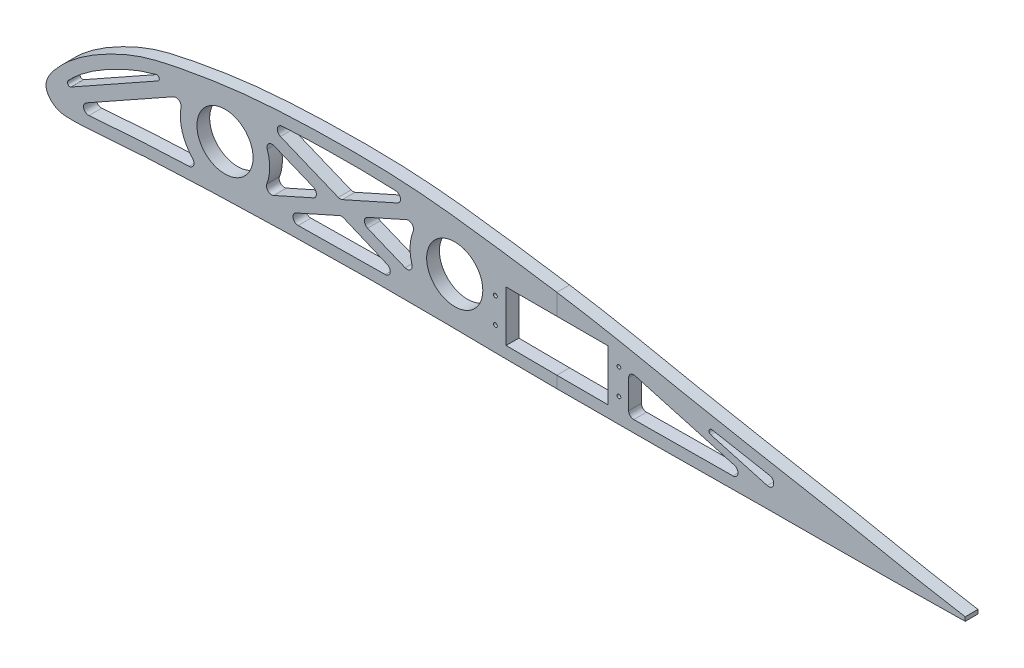
from build123d import *

# Parameters (mm, degrees)
BOSS_EXTRUDE1_DEPTH     = 5
CUT_EXTRUDE2_DEPTH      = 10
SKETCH4_R               = 17.5
SKETCH4_R_2             = 11
BOSS_EXTRUDE2_DEPTH     = 5
BOSS_EXTRUDE3_DEPTH     = 5
BOSS_EXTRUDE4_DEPTH     = 5
BOSS_EXTRUDE9_DEPTH     = 5
FILLET2_R               = 2
FILLET3_R               = 1
BOSS_EXTRUDE10_DEPTH    = 5
SKETCH14_W              = 8
SKETCH14_H              = 21.441661563
BOSS_EXTRUDE11_DEPTH    = 5
FILLET4_R               = 2
BOSS_EXTRUDE12_DEPTH    = 5
FILLET5_R               = 2
FILLET6_R               = 1
SKETCH16_R              = 0.75
CUT_EXTRUDE4_DEPTH      = 1.0000001
CUT_EXTRUDE4_DEPTH_BACK = 6.0000001


with BuildPart() as part:
    # Sketch1 → Boss-Extrude1 (new body)
    with BuildSketch(Plane.XY):
        with BuildLine():
            Line((360, 0.774), (360, -0.774))
            add(Edge.make_bspline(
                [(360, 0.774), (353.974680873, 1.792284795), (341.899248797, 3.833044566), (317.929020834, 8.851485648), (287.800454127, 14.31152914), (251.645923491, 20.899359426), (215.774175638, 28.640535242), (179.624275737, 33.949707805), (143.618362601, 38.740558592), (107.450537249, 38.957420006), (77.339070326, 37.360330574), (53.43614831, 33.395252889), (38.217547337, 30.21895855), (26.446919069, 25.077351893), (17.386036919, 20.224999572), (9.794480251, 14.74990881), (3.541457009, 8.605067884), (-2.481808469, 0.935733711), (3.758000166, -5.413919643), (10.577414917, -5.762608396), (18.080573899, -5.380619552), (27.062252452, -4.605577133), (39.044866108, -3.765326626), (54.039587486, -3.081650204), (78.025962231, -2.161594953), (108.019345031, -1.480638578), (144.02296593, -1.154123719), (180.021438433, -1.808547661), (216.025347982, -1.914735298), (252.023524557, -1.742911881), (288.019222803, -1.265721883), (318.018389876, -1.415424317), (342.010713463, -1.011586311), (354.004770931, -0.853179592), (360, -0.774)],
                knots=[0, 0, 0, 0, 0.024829577, 0.049761327, 0.099504997, 0.149248666, 0.1991036, 0.248559966, 0.297717772, 0.346503418, 0.395330606, 0.419968931, 0.445007851, 0.458170616, 0.471959979, 0.486919666, 0.49537123, 0.509218187, 0.518334927, 0.52451228, 0.536705423, 0.548918461, 0.561124671, 0.58552222, 0.609906959, 0.658670148, 0.707430289, 0.756206934, 0.804971253, 0.853735728, 0.902491753, 0.951255847, 0.975635238, 1, 1, 1, 1], degree=3))
        make_face()
    extrude(amount=BOSS_EXTRUDE1_DEPTH)

    # Sketch3 → Cut-Extrude2 (cut)
    with BuildSketch(Plane.XY.offset(5)):
        with BuildLine():
            Line((284.151170085, 10.305494432), (284.97438112, 10.155756181))
            Line((284.97438112, 10.155756181), (284.97438112, 3.210039728))
            add(Edge.make_bspline(
                [(284.151170085, 10.305494432), (278.127742105, 11.40112791), (266.095184843, 13.597729487), (248.003292126, 17.094140098), (230.029705088, 20.836594904), (212.162502787, 24.302338019), (194.181930719, 27.166184382), (176.038520258, 29.748754007), (157.940971544, 32.162728098), (139.962891875, 33.793820017), (121.882548995, 34.271548705), (103.645827002, 33.996629722), (88.528518141, 33.278803379), (76.549087778, 32.181027706), (67.63563779, 31.044934112), (58.725787146, 29.582140587), (49.75795426, 27.929096132), (42.582766976, 26.26934112), (37.126900833, 24.53639522), (33.125887749, 22.965665736), (29.125508727, 21.145593772), (25.187577728, 19.172032343), (21.394836479, 17.051733876), (17.712359966, 14.718865404), (14.202073007, 12.174775039), (11.030441078, 9.51319779), (8.638705388, 7.125600669), (6.577750806, 4.817142605), (5.325349851, 3.168924423), (4.574662719, 1.765549476), (4.46465281, 1.137836061), (4.481180909, 1.044483363), (4.47844535, 1.00605793), (4.820477948, 0.350635186), (5.60848011, -0.324952954), (6.226697822, -0.65743836), (6.753201024, -0.846261896), (7.853750825, -1.023767615), (10.009849885, -1.051894254), (12.169372909, -1.029946848), (14.35792191, -0.946877624), (16.571440935, -0.821739961), (19.56465248, -0.615487304), (23.340266816, -0.313726761), (27.944482299, 0.059001889), (32.556807022, 0.389548829), (38.709247897, 0.78058095), (46.390199054, 1.176447297), (55.574387547, 1.56959471), (67.816448016, 2.053020476), (83.136164612, 2.543128444), (107.634418814, 3.080623999), (132.139641633, 3.383109743), (156.680105932, 3.198575235), (175.019214124, 2.92236916), (193.318155834, 2.756278199), (217.743894764, 2.7049477), (242.174975987, 2.797198443), (266.603485174, 3.056821248), (278.853612921, 3.175950672), (284.97438112, 3.210039728)],
                knots=[0.103397874, 0.103397874, 0.103397874, 0.103397874, 0.128241805, 0.153085736, 0.177929667, 0.202773598, 0.227617529, 0.252461459, 0.27730539, 0.302149321, 0.326993252, 0.351837183, 0.376681114, 0.389103079, 0.401525045, 0.41394701, 0.426368975, 0.438790941, 0.445001924, 0.451212906, 0.457423889, 0.463634872, 0.469845854, 0.476056837, 0.48226782, 0.488478803, 0.494689785, 0.497795277, 0.500900768, 0.504006259, 0.507111751, 0.508664496, 0.510217242, 0.513322733, 0.516428225, 0.517980971, 0.519533716, 0.522639208, 0.525744699, 0.52885019, 0.531955682, 0.535061173, 0.538166664, 0.544377647, 0.55058863, 0.556799613, 0.563010595, 0.575432561, 0.587854526, 0.600276492, 0.625120422, 0.649964353, 0.699652215, 0.724496146, 0.749340077, 0.774184008, 0.799027938, 0.8487158, 0.873559731, 0.898403662, 0.898403662, 0.898403662, 0.898403662], degree=3))
        make_face()
    extrude(amount=-CUT_EXTRUDE2_DEPTH, mode=Mode.SUBTRACT)

    # Sketch4 → Boss-Extrude2 (add)
    with BuildSketch(Plane.XY.offset(5)):
        with Locations((70, 17)):
            Circle(SKETCH4_R)
        with Locations((70, 17)):
            Circle(SKETCH4_R_2, mode=Mode.SUBTRACT)
        with Locations((160, 17)):
            Circle(SKETCH4_R)
        with Locations((160, 17)):
            Circle(SKETCH4_R_2, mode=Mode.SUBTRACT)
    extrude(amount=-BOSS_EXTRUDE2_DEPTH)

    # Sketch12 → Boss-Extrude9 (add)
    with BuildSketch(Plane.XY.offset(5)):
        Polygon((79.394601196, 34.64026251), (115.166114408, 19.933643537), (150.735654853, 35.839198496), (152.776722305, 31.274766039), (121.547528721, 17.310074658), (150.128535807, 5.559663693), (148.22731033, 0.935234897), (115.643372611, 14.669925859), (81.088004352, -0.782123904), (79.046936899, 3.782308553), (108.867491183, 17.117101726), (77.493375719, 30.015833714), align=None)
        Polygon((4.028219292, 2.180620918), (56.384295431, 31.536283384), (58.82961129, 27.175041548), (6.473535151, -2.180620918), (4.028219292, -2.180620918), align=None)
    extrude(amount=-BOSS_EXTRUDE9_DEPTH)

    # Fillet2
    fillet2_edges = [part.edges().sort_by_distance(p)[0] for p in [
        (61.336439293, 1.794977281, 2.4999988),
        (54.236223938, 24.599563426, 2.5),
        (8.541446673, -1.021158308, 2.5),
        (108.867491183, 17.117101726, 2.5),
        (84.168481456, 27.271520492, 2.5),
        (83.379117252, 5.719520331, 2.5),
        (88.776824691, 2.656069363, 2.5),
        (115.643372611, 14.669925859, 2.5),
        (142.650891312, 3.28579156, 2.5),
        (115.166114408, 19.933643537, 2.5),
        (83.814832721, 32.822987954, 2.5),
        (121.547528721, 17.310074658, 2.5),
        (145.264957292, 7.55920997, 2.5),
        (146.964299295, 28.675637332, 2.5),
        (144.975918521, 33.263629578, 2.5),
        (284.97438112, 10.155756181, 2.5),
    ]]
    fillet(fillet2_edges, radius=FILLET2_R)

    # Fillet3
    fillet3_edges = [part.edges().sort_by_distance(p)[0] for p in [
        (49.869301445, 27.883374715, 2.5),
        (5.162271567, 2.816475593, 2.5),
    ]]
    fillet(fillet3_edges, radius=FILLET3_R)



with BuildPart() as body_2:
    # Sketch7 → Boss-Extrude3 (new body)
    with BuildSketch(Plane.XY.offset(5)):
        Polygon((220.125041468, 22.736341228), (220.125041468, 2.736341228), (228.125041468, 2.757192949), (228.125041468, 21.175556814), align=None)
    extrude(amount=-BOSS_EXTRUDE3_DEPTH)


with BuildPart() as body_3:
    # Sketch8 → Boss-Extrude4 (new body)
    with BuildSketch(Plane.XY.offset(5)):
        with BuildLine():
            Line((220.125041468, 22.736341228), (180.125041468, 22.736341228))
            Line((180.125041468, 22.736341228), (180.125041468, 2.883340625))
            Line((180.125041468, 2.883340625), (170.497252173, 2.997939551))
            ThreePointArc((170.497252173, 2.997939551), (177.492609251, 16.491451493), (171.292976438, 30.368570723))
            add(Edge.make_bspline(
                [(220.125041468, 22.736341228), (217.466155303, 23.241633023), (208.840551898, 24.831440038), (194.181930719, 27.166184382), (180.499321948, 29.113794501), (172.876698141, 30.155766911), (171.292976438, 30.368570723)],
                knots=[0.191699582, 0.191699582, 0.191699582, 0.191699582, 0.202773598, 0.227617529, 0.252461459, 0.258980746, 0.258980746, 0.258980746, 0.258980746], degree=3))
        make_face()
    extrude(amount=-BOSS_EXTRUDE4_DEPTH)


with BuildPart() as part_1:
    add(part.part)

    add(body_3.part)  # Boss-Extrude10 merges body 3
    # Sketch13 → Boss-Extrude10 (add)
    with BuildSketch(Plane.XY.offset(5)):
        Polygon((180.125041468, 10.599966528), (180.125041468, 1.04788629), (168.103999707, 1.416563071), (171.891315732, 7.784616563), (174.729224235, 21.275196194), (168.934617904, 28.499624812), (169.827611237, 32.744651618), (180.125041468, 30.578461163), align=None)
    extrude(amount=-BOSS_EXTRUDE10_DEPTH)


    add(body_2.part)  # Boss-Extrude11 merges body 2
    # Sketch14 → Boss-Extrude11 (add)
    with BuildSketch(Plane.XY.offset(5)):
        with Locations((224.125041468, 12.015510447)):
            Rectangle(SKETCH14_W, SKETCH14_H)
    extrude(amount=-BOSS_EXTRUDE11_DEPTH)

    # Fillet4
    fillet4_edges = [part_1.edges().sort_by_distance(p)[0] for p in [
        (228.125041468, 2.757192949, 2.5),
    ]]
    fillet(fillet4_edges, radius=FILLET4_R)

    # Sketch15 → Boss-Extrude12 (add)
    with BuildSketch(Plane.XY.offset(5)):
        Polygon((227.43699621, 18.776993458), (284.854439468, 2.719458378), (285.662426378, 5.608603088), (228.244983119, 21.666138168), align=None)
    extrude(amount=-BOSS_EXTRUDE12_DEPTH)

    # Fillet5
    fillet5_edges = [part_1.edges().sort_by_distance(p)[0] for p in [
        (284.97438112, 5.801023897, 2.5),
        (283.139439325, 3.199080483, 2.5),
        (228.125041468, 18.584572649, 2.5),
    ]]
    fillet(fillet5_edges, radius=FILLET5_R)

    # Fillet6
    fillet6_edges = [part_1.edges().sort_by_distance(p)[0] for p in [
        (234.874204475, 19.812190161, 2.5),
    ]]
    fillet(fillet6_edges, radius=FILLET6_R)

    # Sketch16 → Cut-Extrude4 (cut, two sides)
    with BuildSketch(Plane.XY.offset(5)) as cut_extrude4_sk:
        with Locations((224.325041468, 17.736341228)):
            Circle(SKETCH16_R)
        with Locations((224.325041468, 7.736341228)):
            Circle(SKETCH16_R)
        with Locations((175.925041468, 17.736341228)):
            Circle(SKETCH16_R)
        with Locations((175.925041468, 7.736341228)):
            Circle(SKETCH16_R)
    extrude(amount=CUT_EXTRUDE4_DEPTH, mode=Mode.SUBTRACT)
    extrude(cut_extrude4_sk.sketch, amount=-CUT_EXTRUDE4_DEPTH_BACK, mode=Mode.SUBTRACT)


with BuildPart() as body_2_2:
    # Split1: the piece on the far side of the plane
    add(part_1.part)
    split(bisect_by=Plane(origin=(200, 0, 0), x_dir=(0, 0, 1), z_dir=(1, 0, 0)), keep=Keep.BOTTOM)


with BuildPart() as part_2:
    add(part_1.part)

    # Split1
    split(bisect_by=Plane(origin=(200, 0, 0), x_dir=(0, 0, 1), z_dir=(1, 0, 0)), keep=Keep.TOP)


solid = Compound([body_2_2.part, part_2.part])
